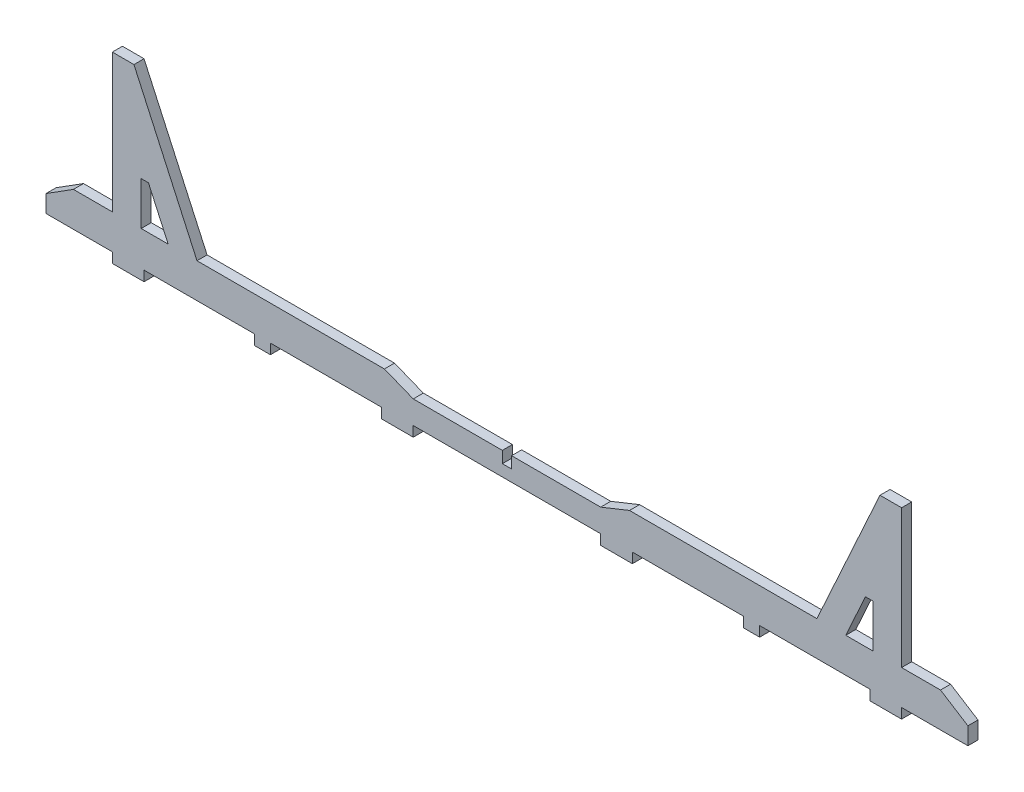
from build123d import *

# Parameters (mm, degrees)
BOSS_EXTRUDE1_DEPTH = 3.5


with BuildPart() as part:
    # Sketch1 → Boss-Extrude1 (new body)
    with BuildSketch(Plane.XY):
        Polygon((75, 12), (96.871, 60), (104.371, 60), (104.371, 12), (108.371, 12), (117.871, 12), (127.371, 6), (127.371, 0), (112.371, 0), (104.371, 0), (104.371, -3.5), (93.371, -3.5), (93.371, 0), (55.135445, 0), (55.135445, -3.5), (49.535445, -3.5), (49.535445, 0), (11, 0), (11, -3.5), (0, -3.5), (0, 0), (-65, 0), (-65, -3.5), (-76, -3.5), (-76, 0), (-114.535445, 0), (-114.535445, -3.5), (-120.135445, -3.5), (-120.135445, 0), (-158.371, 0), (-158.371, -3.5), (-169.371, -3.5), (-169.371, 0), (-177.371, 0), (-192.371, 0), (-192.371, 6), (-182.871, 12), (-173.371, 12), (-169.371, 12), (-169.371, 60), (-161.871, 60), (-140, 12), (-75, 12), (-65, 8), (-34.1, 8), (-34.1, 4), (-30.9, 4), (-30.9, 8), (0, 8), (10, 12), align=None)
        Polygon((85, 12), (91.8346875, 27), (94.371, 27), (94.371, 12), align=None, mode=Mode.SUBTRACT)
        Polygon((-150, 12), (-159.371, 12), (-159.371, 27), (-156.8346875, 27), align=None, mode=Mode.SUBTRACT)
    extrude(amount=BOSS_EXTRUDE1_DEPTH)


solid = part.part
